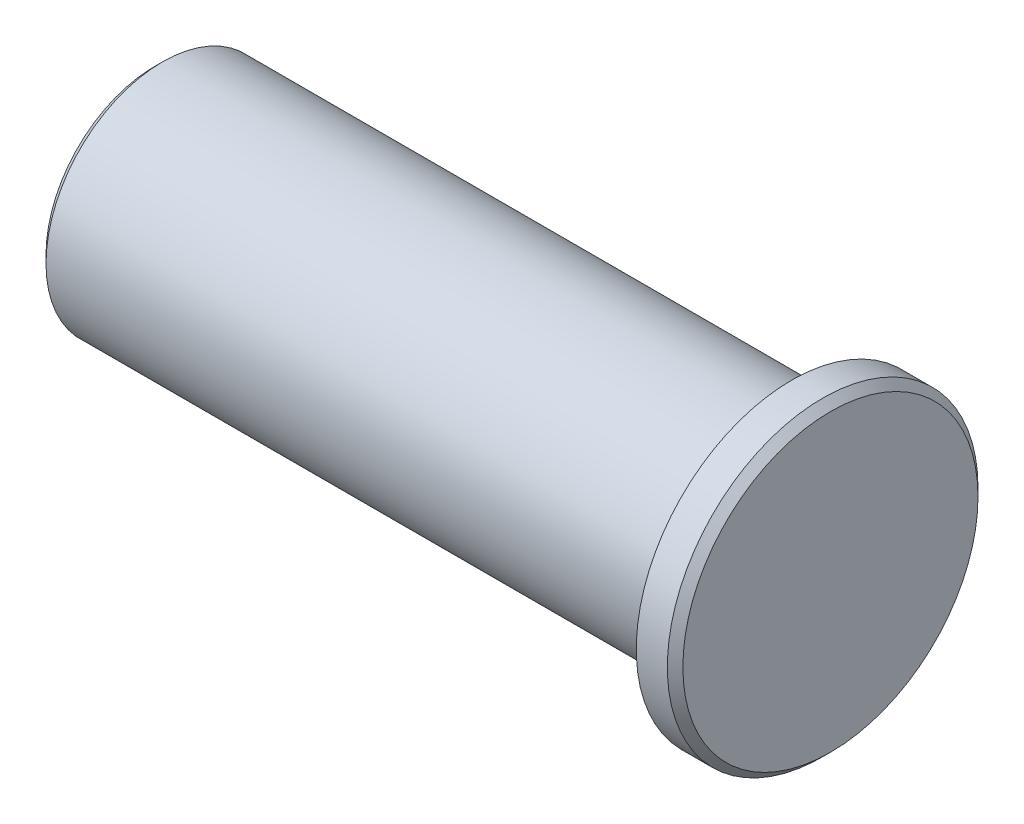
from build123d import *

# Parameters (mm, degrees)
SKETCH_1_R             = 15
EXTRUDE_1_DEPTH        = 82
SKETCH_2_R             = 20
EXTRUDE_2_DEPTH        = 5
CHAMFER_1_SIZE         = 1
HOLE_WIZARD_M8_1_D     = 6.8
HOLE_WIZARD_M8_1_DEPTH = 15
HOLE_WIZARD_M8_1_TIP   = 2.042926105


with BuildPart() as part:
    # 草图1 → 凸台-拉伸1 (new body)
    with BuildSketch(Plane(origin=(0, 0, 0), x_dir=(0, 0, -1), z_dir=(1, 0, 0))):
        Circle(SKETCH_1_R)
    extrude(amount=EXTRUDE_1_DEPTH)

    # 草图2 → 凸台-拉伸2 (add)
    with BuildSketch(Plane(origin=(82, 0, 0), x_dir=(0, 0, -1), z_dir=(1, 0, 0))):
        Circle(SKETCH_2_R)
    extrude(amount=EXTRUDE_2_DEPTH)

    # 倒角1
    chamfer_1_edges = [part.edges().sort_by_distance(p)[0] for p in [
        (0, 0, 15),
        (87, 0, 20),
    ]]
    chamfer(chamfer_1_edges, length=CHAMFER_1_SIZE)

    # M8 螺纹孔的螺纹孔钻头1
    with Locations(Plane(origin=(0, 0, 0), x_dir=(0, 0, -1), z_dir=(-1, 0, 0))):
        with Locations((0, 0)):
            Hole(HOLE_WIZARD_M8_1_D / 2, depth=HOLE_WIZARD_M8_1_DEPTH)
            with Locations((0, 0, -(HOLE_WIZARD_M8_1_DEPTH + HOLE_WIZARD_M8_1_TIP / 2))):  # 118° drill point
                Cone(0, HOLE_WIZARD_M8_1_D / 2, HOLE_WIZARD_M8_1_TIP, mode=Mode.SUBTRACT)


solid = part.part
